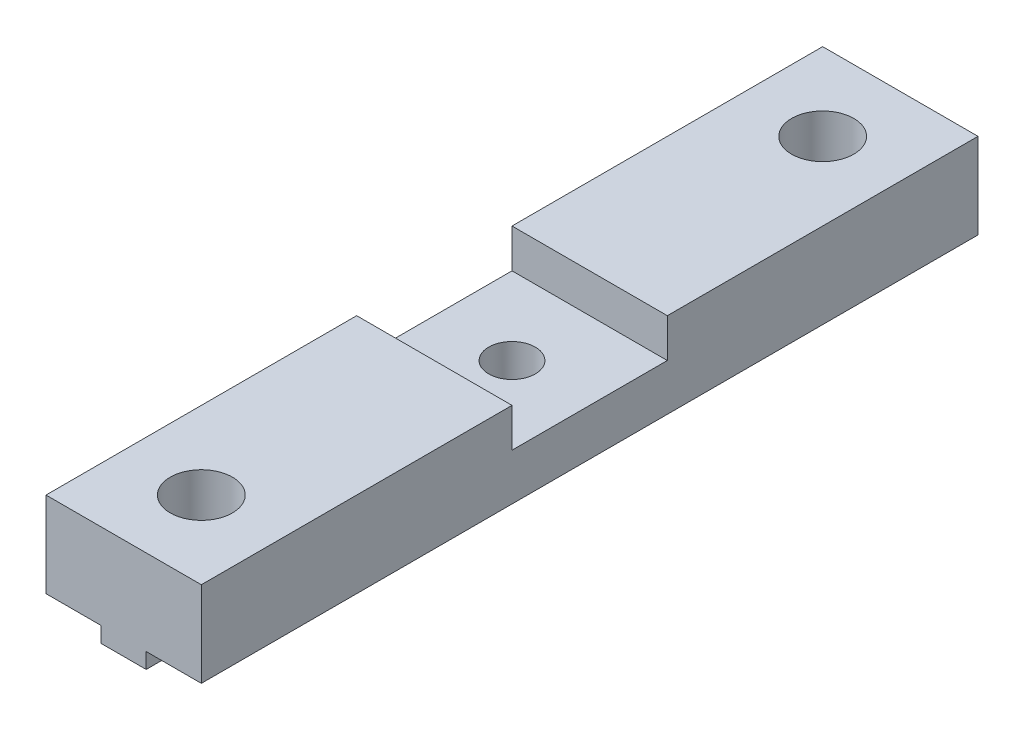
from build123d import *

# Parameters (mm, degrees)
MAIN_DEPTH         = 25
SKETCH2_R          = 2
SKETCH2_R_2        = 1.5
HOLES_DEPTH        = 7.5
SKETCH3_W          = 10
SKETCH3_H          = 2.5
CUT_EXTRUDE2_DEPTH = 11


with BuildPart() as part:
    # Sketch1 → Main (new body, symmetric)
    with BuildSketch(Plane.XY):
        Polygon((-5, 0), (5, 0), (5, -5.5), (1.45, -5.5), (1.45, -6.5), (-1.45, -6.5), (-1.45, -5.5), (-5, -5.5), align=None)
    extrude(amount=MAIN_DEPTH, both=True)

    # Sketch2 → Holes (cut, through all)
    with BuildSketch(Plane(origin=(0, 0, 0), x_dir=(1, 0, 0), z_dir=(0, 1, 0))):
        with Locations((0, 20)):
            Circle(SKETCH2_R)
        with Locations((0, -20)):
            Circle(SKETCH2_R)
        Circle(SKETCH2_R_2)
    extrude(amount=-HOLES_DEPTH, mode=Mode.SUBTRACT)

    # Sketch3 → Cut-Extrude2 (cut, through all)
    with BuildSketch(Plane.ZY.offset(5)):
        with Locations((0, -1.25)):
            Rectangle(SKETCH3_W, SKETCH3_H)
    extrude(amount=-CUT_EXTRUDE2_DEPTH, mode=Mode.SUBTRACT)


solid = part.part
